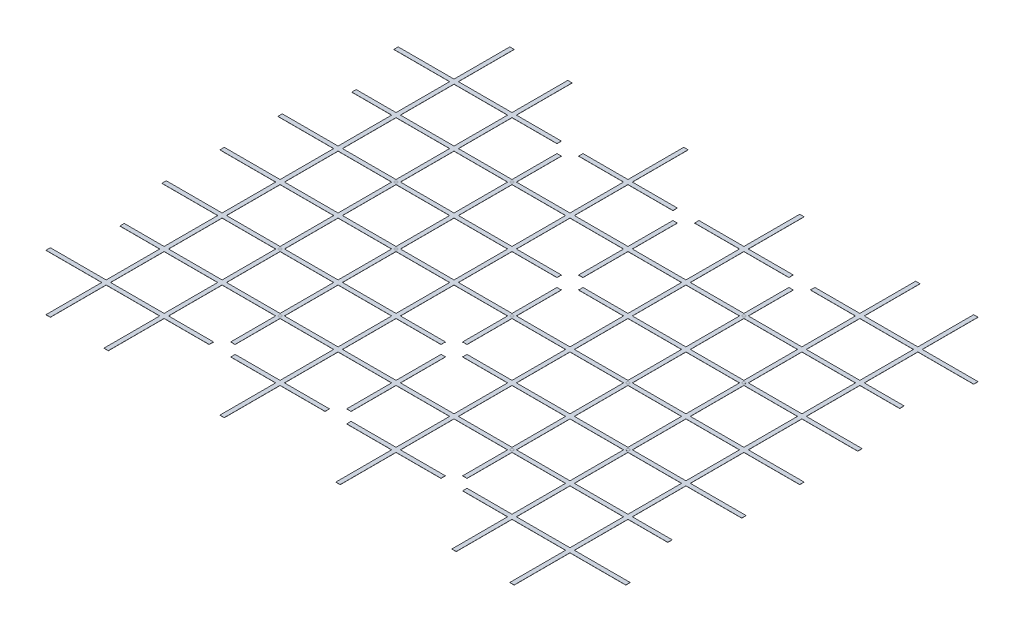
from build123d import *

# Parameters (mm, degrees)
SKETCH_1_W          = 4000
SKETCH_1_H          = 3200
EXTRUDE_1_DEPTH     = 1
SKETCH_2_W          = 370
SKETCH_2_H          = 370
CUT_EXTRUDE_2_DEPTH = 2
SKETCH_4_W          = 385
SKETCH_4_H          = 385
CUT_EXTRUDE_4_DEPTH = 2
SKETCH_5_W          = 370
SKETCH_5_H          = 15
SKETCH_5_W_2        = 15
SKETCH_5_H_2        = 370
CUT_EXTRUDE_5_DEPTH = 2
SKETCH_6_R          = 75
SKETCH_6_W          = 110
SKETCH_6_H          = 30
CUT_EXTRUDE_6_DEPTH = 2
SKETCH_7_R          = 10
EXTRUDE_2_DEPTH     = 0.1


with BuildPart() as part:
    # 草图1 → 凸台-拉伸1 (new body)
    with BuildSketch(Plane(origin=(0, 0, 0), x_dir=(1, 0, 0), z_dir=(0, 1, 0))):
        with Locations((2000, 1600)):
            Rectangle(SKETCH_1_W, SKETCH_1_H)
    extrude(amount=EXTRUDE_1_DEPTH)

    # 草图2 → 切除-拉伸2 (cut, through all)
    with BuildSketch(Plane(origin=(0, 1, 0), x_dir=(1, 0, 0), z_dir=(0, 1, 0))):
        with Locations((200, 200)):
            Rectangle(SKETCH_2_W, SKETCH_2_H)
        with Locations((600, 200)):
            Rectangle(SKETCH_2_W, SKETCH_2_H)
        with Locations((1000, 200)):
            Rectangle(SKETCH_2_W, SKETCH_2_H)
        with Locations((1400, 200)):
            Rectangle(SKETCH_2_W, SKETCH_2_H)
        with Locations((1800, 200)):
            Rectangle(SKETCH_2_W, SKETCH_2_H)
        with Locations((2200, 200)):
            Rectangle(SKETCH_2_W, SKETCH_2_H)
        with Locations((2600, 200)):
            Rectangle(SKETCH_2_W, SKETCH_2_H)
        with Locations((3000, 200)):
            Rectangle(SKETCH_2_W, SKETCH_2_H)
        with Locations((3400, 200)):
            Rectangle(SKETCH_2_W, SKETCH_2_H)
        with Locations((3800, 200)):
            Rectangle(SKETCH_2_W, SKETCH_2_H)
        with Locations((600, 600)):
            Rectangle(SKETCH_2_W, SKETCH_2_H)
        with Locations((1000, 600)):
            Rectangle(SKETCH_2_W, SKETCH_2_H)
        with Locations((1400, 600)):
            Rectangle(SKETCH_2_W, SKETCH_2_H)
        with Locations((1800, 600)):
            Rectangle(SKETCH_2_W, SKETCH_2_H)
        with Locations((2200, 600)):
            Rectangle(SKETCH_2_W, SKETCH_2_H)
        with Locations((2600, 600)):
            Rectangle(SKETCH_2_W, SKETCH_2_H)
        with Locations((3000, 600)):
            Rectangle(SKETCH_2_W, SKETCH_2_H)
        with Locations((3400, 600)):
            Rectangle(SKETCH_2_W, SKETCH_2_H)
        with Locations((3800, 600)):
            Rectangle(SKETCH_2_W, SKETCH_2_H)
        with Locations((600, 1000)):
            Rectangle(SKETCH_2_W, SKETCH_2_H)
        with Locations((1000, 1000)):
            Rectangle(SKETCH_2_W, SKETCH_2_H)
        with Locations((1400, 1000)):
            Rectangle(SKETCH_2_W, SKETCH_2_H)
        with Locations((1800, 1000)):
            Rectangle(SKETCH_2_W, SKETCH_2_H)
        with Locations((2200, 1000)):
            Rectangle(SKETCH_2_W, SKETCH_2_H)
        with Locations((2600, 1000)):
            Rectangle(SKETCH_2_W, SKETCH_2_H)
        with Locations((3000, 1000)):
            Rectangle(SKETCH_2_W, SKETCH_2_H)
        with Locations((3400, 1000)):
            Rectangle(SKETCH_2_W, SKETCH_2_H)
        with Locations((3800, 1000)):
            Rectangle(SKETCH_2_W, SKETCH_2_H)
        with Locations((600, 1400)):
            Rectangle(SKETCH_2_W, SKETCH_2_H)
        with Locations((1000, 1400)):
            Rectangle(SKETCH_2_W, SKETCH_2_H)
        with Locations((1400, 1400)):
            Rectangle(SKETCH_2_W, SKETCH_2_H)
        with Locations((1800, 1400)):
            Rectangle(SKETCH_2_W, SKETCH_2_H)
        with Locations((2200, 1400)):
            Rectangle(SKETCH_2_W, SKETCH_2_H)
        with Locations((2600, 1400)):
            Rectangle(SKETCH_2_W, SKETCH_2_H)
        with Locations((3000, 1400)):
            Rectangle(SKETCH_2_W, SKETCH_2_H)
        with Locations((3400, 1400)):
            Rectangle(SKETCH_2_W, SKETCH_2_H)
        with Locations((3800, 1400)):
            Rectangle(SKETCH_2_W, SKETCH_2_H)
        with Locations((600, 1800)):
            Rectangle(SKETCH_2_W, SKETCH_2_H)
        with Locations((1000, 1800)):
            Rectangle(SKETCH_2_W, SKETCH_2_H)
        with Locations((1400, 1800)):
            Rectangle(SKETCH_2_W, SKETCH_2_H)
        with Locations((1800, 1800)):
            Rectangle(SKETCH_2_W, SKETCH_2_H)
        with Locations((2200, 1800)):
            Rectangle(SKETCH_2_W, SKETCH_2_H)
        with Locations((2600, 1800)):
            Rectangle(SKETCH_2_W, SKETCH_2_H)
        with Locations((3000, 1800)):
            Rectangle(SKETCH_2_W, SKETCH_2_H)
        with Locations((3400, 1800)):
            Rectangle(SKETCH_2_W, SKETCH_2_H)
        with Locations((3800, 1800)):
            Rectangle(SKETCH_2_W, SKETCH_2_H)
        with Locations((600, 2200)):
            Rectangle(SKETCH_2_W, SKETCH_2_H)
        with Locations((1000, 2200)):
            Rectangle(SKETCH_2_W, SKETCH_2_H)
        with Locations((1400, 2200)):
            Rectangle(SKETCH_2_W, SKETCH_2_H)
        with Locations((1800, 2200)):
            Rectangle(SKETCH_2_W, SKETCH_2_H)
        with Locations((2200, 2200)):
            Rectangle(SKETCH_2_W, SKETCH_2_H)
        with Locations((2600, 2200)):
            Rectangle(SKETCH_2_W, SKETCH_2_H)
        with Locations((3000, 2200)):
            Rectangle(SKETCH_2_W, SKETCH_2_H)
        with Locations((3400, 2200)):
            Rectangle(SKETCH_2_W, SKETCH_2_H)
        with Locations((3800, 2200)):
            Rectangle(SKETCH_2_W, SKETCH_2_H)
        with Locations((600, 2600)):
            Rectangle(SKETCH_2_W, SKETCH_2_H)
        with Locations((1000, 2600)):
            Rectangle(SKETCH_2_W, SKETCH_2_H)
        with Locations((1400, 2600)):
            Rectangle(SKETCH_2_W, SKETCH_2_H)
        with Locations((1800, 2600)):
            Rectangle(SKETCH_2_W, SKETCH_2_H)
        with Locations((2200, 2600)):
            Rectangle(SKETCH_2_W, SKETCH_2_H)
        with Locations((2600, 2600)):
            Rectangle(SKETCH_2_W, SKETCH_2_H)
        with Locations((3000, 2600)):
            Rectangle(SKETCH_2_W, SKETCH_2_H)
        with Locations((3400, 2600)):
            Rectangle(SKETCH_2_W, SKETCH_2_H)
        with Locations((3800, 2600)):
            Rectangle(SKETCH_2_W, SKETCH_2_H)
        with Locations((600, 3000)):
            Rectangle(SKETCH_2_W, SKETCH_2_H)
        with Locations((1000, 3000)):
            Rectangle(SKETCH_2_W, SKETCH_2_H)
        with Locations((1400, 3000)):
            Rectangle(SKETCH_2_W, SKETCH_2_H)
        with Locations((1800, 3000)):
            Rectangle(SKETCH_2_W, SKETCH_2_H)
        with Locations((2200, 3000)):
            Rectangle(SKETCH_2_W, SKETCH_2_H)
        with Locations((2600, 3000)):
            Rectangle(SKETCH_2_W, SKETCH_2_H)
        with Locations((3000, 3000)):
            Rectangle(SKETCH_2_W, SKETCH_2_H)
        with Locations((3400, 3000)):
            Rectangle(SKETCH_2_W, SKETCH_2_H)
        with Locations((3800, 3000)):
            Rectangle(SKETCH_2_W, SKETCH_2_H)
        with Locations((200, 600)):
            Rectangle(SKETCH_2_W, SKETCH_2_H)
        with Locations((200, 1000)):
            Rectangle(SKETCH_2_W, SKETCH_2_H)
        with Locations((200, 1400)):
            Rectangle(SKETCH_2_W, SKETCH_2_H)
        with Locations((200, 1800)):
            Rectangle(SKETCH_2_W, SKETCH_2_H)
        with Locations((200, 2200)):
            Rectangle(SKETCH_2_W, SKETCH_2_H)
        with Locations((200, 2600)):
            Rectangle(SKETCH_2_W, SKETCH_2_H)
        with Locations((200, 3000)):
            Rectangle(SKETCH_2_W, SKETCH_2_H)
    extrude(amount=-CUT_EXTRUDE_2_DEPTH, mode=Mode.SUBTRACT)

    # 草图4 → 切除-拉伸4 (cut, through all)
    with BuildSketch(Plane(origin=(0, 1, 0), x_dir=(1, 0, 0), z_dir=(0, 1, 0))):
        with Locations((192.5, 3007.5)):
            Rectangle(SKETCH_4_W, SKETCH_4_H)
        with Locations((3807.5, 3007.5)):
            Rectangle(SKETCH_4_W, SKETCH_4_H)
        with Locations((3807.5, 192.5)):
            Rectangle(SKETCH_4_W, SKETCH_4_H)
        with Locations((192.5, 192.5)):
            Rectangle(SKETCH_4_W, SKETCH_4_H)
    extrude(amount=-CUT_EXTRUDE_4_DEPTH, mode=Mode.SUBTRACT)

    # 草图5 → 切除-拉伸5 (cut, through all)
    with BuildSketch(Plane(origin=(0, 1, 0), x_dir=(1, 0, 0), z_dir=(0, 1, 0))):
        with Locations((600, 7.5)):
            Rectangle(SKETCH_5_W, SKETCH_5_H)
        with Locations((1000, 7.5)):
            Rectangle(SKETCH_5_W, SKETCH_5_H)
        with Locations((1400, 7.5)):
            Rectangle(SKETCH_5_W, SKETCH_5_H)
        with Locations((1800, 7.5)):
            Rectangle(SKETCH_5_W, SKETCH_5_H)
        with Locations((2200, 7.5)):
            Rectangle(SKETCH_5_W, SKETCH_5_H)
        with Locations((2600, 7.5)):
            Rectangle(SKETCH_5_W, SKETCH_5_H)
        with Locations((3000, 7.5)):
            Rectangle(SKETCH_5_W, SKETCH_5_H)
        with Locations((3400, 7.5)):
            Rectangle(SKETCH_5_W, SKETCH_5_H)
        with Locations((1000, 3192.5)):
            Rectangle(SKETCH_5_W, SKETCH_5_H)
        with Locations((1400, 3192.5)):
            Rectangle(SKETCH_5_W, SKETCH_5_H)
        with Locations((1800, 3192.5)):
            Rectangle(SKETCH_5_W, SKETCH_5_H)
        with Locations((2200, 3192.5)):
            Rectangle(SKETCH_5_W, SKETCH_5_H)
        with Locations((2600, 3192.5)):
            Rectangle(SKETCH_5_W, SKETCH_5_H)
        with Locations((3000, 3192.5)):
            Rectangle(SKETCH_5_W, SKETCH_5_H)
        with Locations((3400, 3192.5)):
            Rectangle(SKETCH_5_W, SKETCH_5_H)
        with Locations((600, 3192.5)):
            Rectangle(SKETCH_5_W, SKETCH_5_H)
        with Locations((7.5, 600)):
            Rectangle(SKETCH_5_W_2, SKETCH_5_H_2)
        with Locations((3992.5, 600)):
            Rectangle(SKETCH_5_W_2, SKETCH_5_H_2)
        with Locations((3992.5, 1000)):
            Rectangle(SKETCH_5_W_2, SKETCH_5_H_2)
        with Locations((3992.5, 1400)):
            Rectangle(SKETCH_5_W_2, SKETCH_5_H_2)
        with Locations((3992.5, 1800)):
            Rectangle(SKETCH_5_W_2, SKETCH_5_H_2)
        with Locations((3992.5, 2200)):
            Rectangle(SKETCH_5_W_2, SKETCH_5_H_2)
        with Locations((3992.5, 2600)):
            Rectangle(SKETCH_5_W_2, SKETCH_5_H_2)
        with Locations((7.5, 1000)):
            Rectangle(SKETCH_5_W_2, SKETCH_5_H_2)
        with Locations((7.5, 1400)):
            Rectangle(SKETCH_5_W_2, SKETCH_5_H_2)
        with Locations((7.5, 1800)):
            Rectangle(SKETCH_5_W_2, SKETCH_5_H_2)
        with Locations((7.5, 2200)):
            Rectangle(SKETCH_5_W_2, SKETCH_5_H_2)
        with Locations((7.5, 2600)):
            Rectangle(SKETCH_5_W_2, SKETCH_5_H_2)
    extrude(amount=-CUT_EXTRUDE_5_DEPTH, mode=Mode.SUBTRACT)

    # 草图6 → 切除-拉伸6 (cut, through all)
    with BuildSketch(Plane(origin=(0, 1, 0), x_dir=(1, 0, 0), z_dir=(0, 1, 0))):
        with Locations((2000, 2000)):
            Circle(SKETCH_6_R)
        with Locations((2000, 1200)):
            Circle(SKETCH_6_R)
        with Locations((55, 2400)):
            Rectangle(SKETCH_6_W, SKETCH_6_H)
        with Locations((55, 800)):
            Rectangle(SKETCH_6_W, SKETCH_6_H)
        with Locations((3945, 800)):
            Rectangle(SKETCH_6_W, SKETCH_6_H)
        with Locations((3945, 2400)):
            Rectangle(SKETCH_6_W, SKETCH_6_H)
        with BuildLine():
            Line((1125, 3200), (1275, 3200))
            Line((1275, 3200), (1275, 2800))
            ThreePointArc((1275, 2800), (1200, 2725), (1125, 2800))
            Line((1125, 2800), (1125, 3200))
        make_face()
        with BuildLine():
            Line((1925, 3200), (2075, 3200))
            Line((2075, 3200), (2075, 2800))
            ThreePointArc((2075, 2800), (2000, 2725), (1925, 2800))
            Line((1925, 2800), (1925, 3200))
        make_face()
        with BuildLine():
            Line((2725, 3200), (2875, 3200))
            Line((2875, 3200), (2875, 2800))
            ThreePointArc((2875, 2800), (2800, 2725), (2725, 2800))
            Line((2725, 2800), (2725, 3200))
        make_face()
        with BuildLine():
            Line((2875, 0), (2875, 400))
            ThreePointArc((2875, 400), (2800, 475), (2725, 400))
            Line((2725, 400), (2725, 0))
            Line((2725, 0), (2875, 0))
        make_face()
        with BuildLine():
            Line((2075, 0), (2075, 400))
            ThreePointArc((2075, 400), (2000, 475), (1925, 400))
            Line((1925, 400), (1925, 0))
            Line((1925, 0), (2075, 0))
        make_face()
        with BuildLine():
            Line((1275, 0), (1275, 400))
            ThreePointArc((1275, 400), (1200, 475), (1125, 400))
            Line((1125, 400), (1125, 0))
            Line((1125, 0), (1275, 0))
        make_face()
    extrude(amount=-CUT_EXTRUDE_6_DEPTH, mode=Mode.SUBTRACT)

    # 草图7 → 凸台-拉伸2 (add)
    with BuildSketch(Plane(origin=(0, 1, 0), x_dir=(1, 0, 0), z_dir=(0, 1, 0))):
        with Locations((1200, 2400)):
            Circle(SKETCH_7_R)
        with Locations((1200, 1600)):
            Circle(SKETCH_7_R)
        with Locations((1200, 800)):
            Circle(SKETCH_7_R)
        with Locations((800, 2000)):
            Circle(SKETCH_7_R)
        with Locations((800, 1200)):
            Circle(SKETCH_7_R)
        with Locations((2000, 1600)):
            Circle(SKETCH_7_R)
        with Locations((2800, 800)):
            Circle(SKETCH_7_R)
        with Locations((3200, 1200)):
            Circle(SKETCH_7_R)
        with Locations((2800, 1600)):
            Circle(SKETCH_7_R)
        with Locations((3200, 2000)):
            Circle(SKETCH_7_R)
        with Locations((2800, 2400)):
            Circle(SKETCH_7_R)
    extrude(amount=EXTRUDE_2_DEPTH)


solid = part.part
